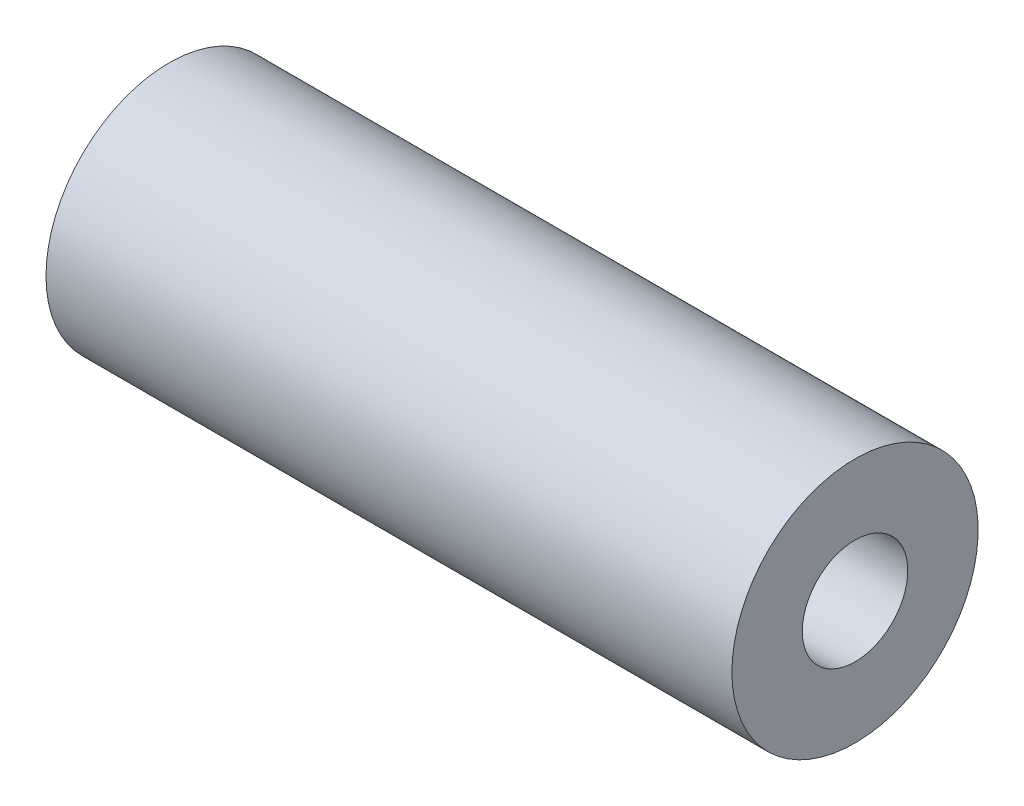
from build123d import *

# Parameters (mm, degrees)
SKETCH1_W = 39
SKETCH1_H = 4


with BuildPart() as part:
    # Sketch1 → Revolve1 (revolve)
    with BuildSketch(Plane.XY):
        with Locations((0, 5)):
            Rectangle(SKETCH1_W, SKETCH1_H)
    revolve(axis=Axis((-37.003163219, 0, 0), (1, 0, 0)))


solid = part.part
